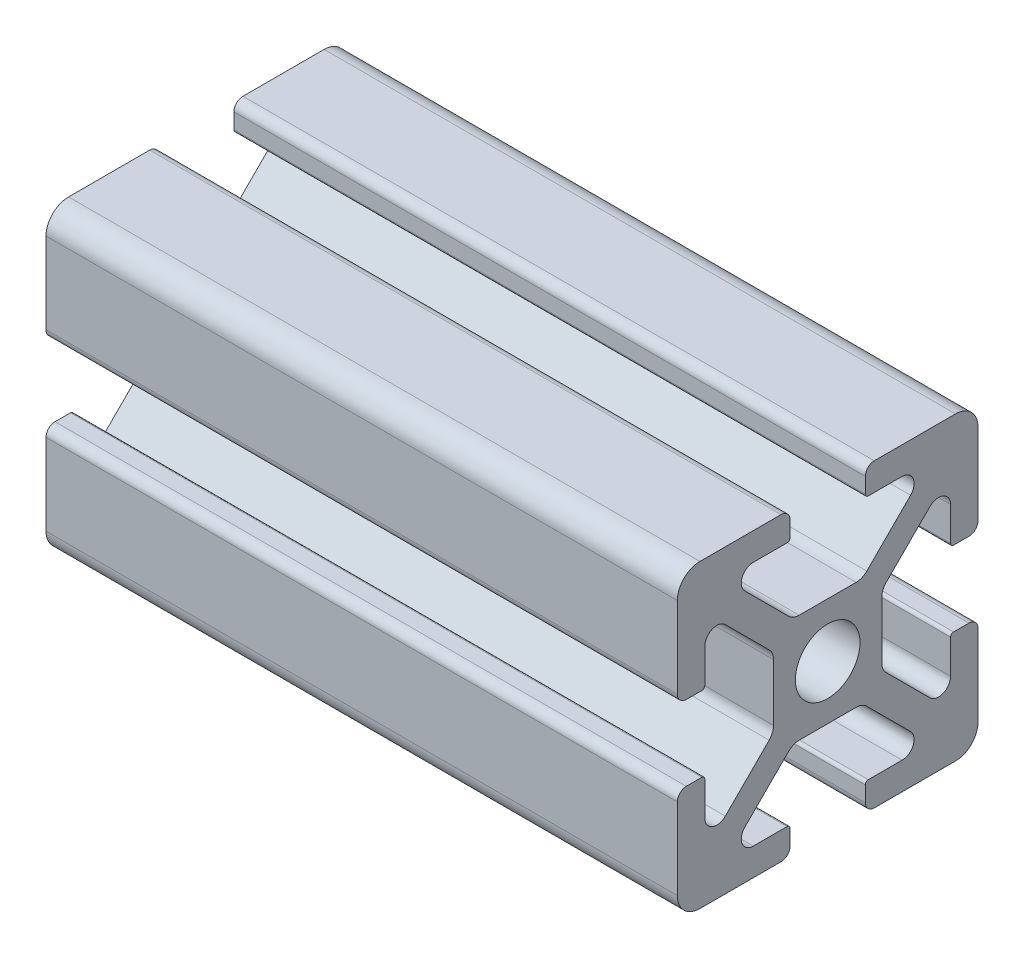
from build123d import *

# Parameters (mm, degrees)
BOSS_EXTRUDE1_DEPTH = 42


with BuildPart() as part:
    # Sketch3 → Boss-Extrude1 (new body)
    with BuildSketch(Plane(origin=(0, 0, 0), x_dir=(0, 0, -1), z_dir=(1, 0, 0))):
        with BuildLine():
            Line((-5.515685425, 6.807463915), (-2.601114729, 3.892893219))
            ThreePointArc((-2.601114729, 3.892893219), (-2.27669138, 3.676120467), (-1.894007948, 3.6))
            Line((-1.894007948, 3.6), (0, 3.6))
            Line((0, 3.6), (0, 2.15))
            ThreePointArc((0, 2.15), (-1.52027958, 1.52027958), (-2.15, 0))
            Line((-2.15, 0), (-3.6, 0))
            Line((-3.6, 0), (-3.6, 1.894007948))
            ThreePointArc((-3.6, 1.894007948), (-3.676120467, 2.27669138), (-3.892893219, 2.601114729))
            Line((-3.892893219, 2.601114729), (-6.807463915, 5.515685425))
            ThreePointArc((-6.807463915, 5.515685425), (-7.679296086, 5.689103626), (-8.17314934, 4.95))
            Line((-8.17314934, 4.95), (-8.17314934, 2.7))
            ThreePointArc((-8.17314934, 2.7), (-8.231727984, 2.558578644), (-8.37314934, 2.5))
            Line((-8.37314934, 2.5), (-9.4, 2.5))
            ThreePointArc((-9.4, 2.5), (-9.824264069, 2.675735931), (-10, 3.1))
            Line((-10, 3.1), (-10, 8.5))
            ThreePointArc((-10, 8.5), (-9.560660172, 9.560660172), (-8.5, 10))
            Line((-8.5, 10), (-3.1, 10))
            ThreePointArc((-3.1, 10), (-2.675735931, 9.824264069), (-2.5, 9.4))
            Line((-2.5, 9.4), (-2.5, 8.37314934))
            ThreePointArc((-2.5, 8.37314934), (-2.558578644, 8.231727984), (-2.7, 8.17314934))
            Line((-2.7, 8.17314934), (-4.95, 8.17314934))
            ThreePointArc((-4.95, 8.17314934), (-5.689103626, 7.679296086), (-5.515685425, 6.807463915))
        make_face()
    extrude(amount=-BOSS_EXTRUDE1_DEPTH)

    # Mirror1: part across plane


with BuildPart() as part_1:
    add(part.part)
    add(part.part.mirror(Plane.ZX))

    # Mirror2: part across plane


with BuildPart() as part_2:
    add(part_1.part)
    add(part_1.part.mirror(Plane.XY))


solid = part_2.part
